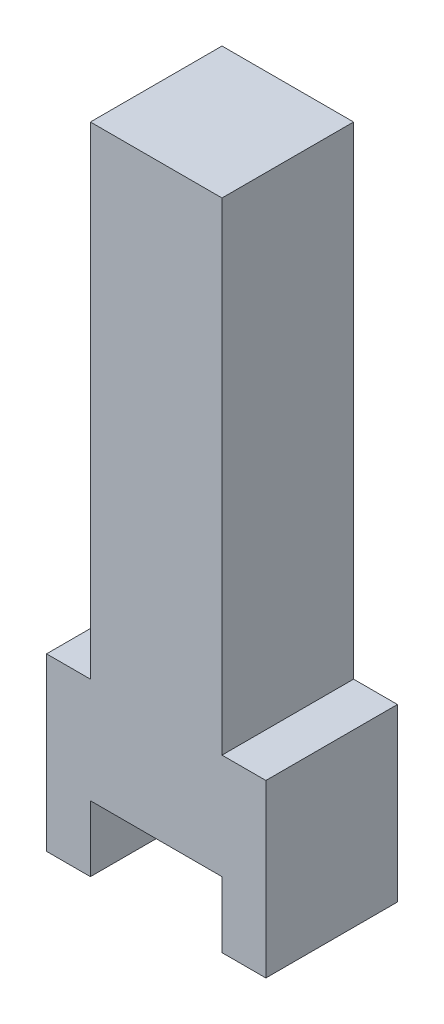
from build123d import *

# Parameters (mm, degrees)
BOSS_EXTRUDE1_DEPTH = 3


with BuildPart() as part:
    # Sketch2 → Boss-Extrude1 (new body)
    with BuildSketch(Plane.XY):
        Polygon((4, -3.9), (5, -3.9), (5, 0), (4, 0), (4, 11), (1, 11), (1, 0), (0, 0), (0, -3.9), (1, -3.9), (1, -2.4), (4, -2.4), align=None)
    extrude(amount=BOSS_EXTRUDE1_DEPTH)


solid = part.part
